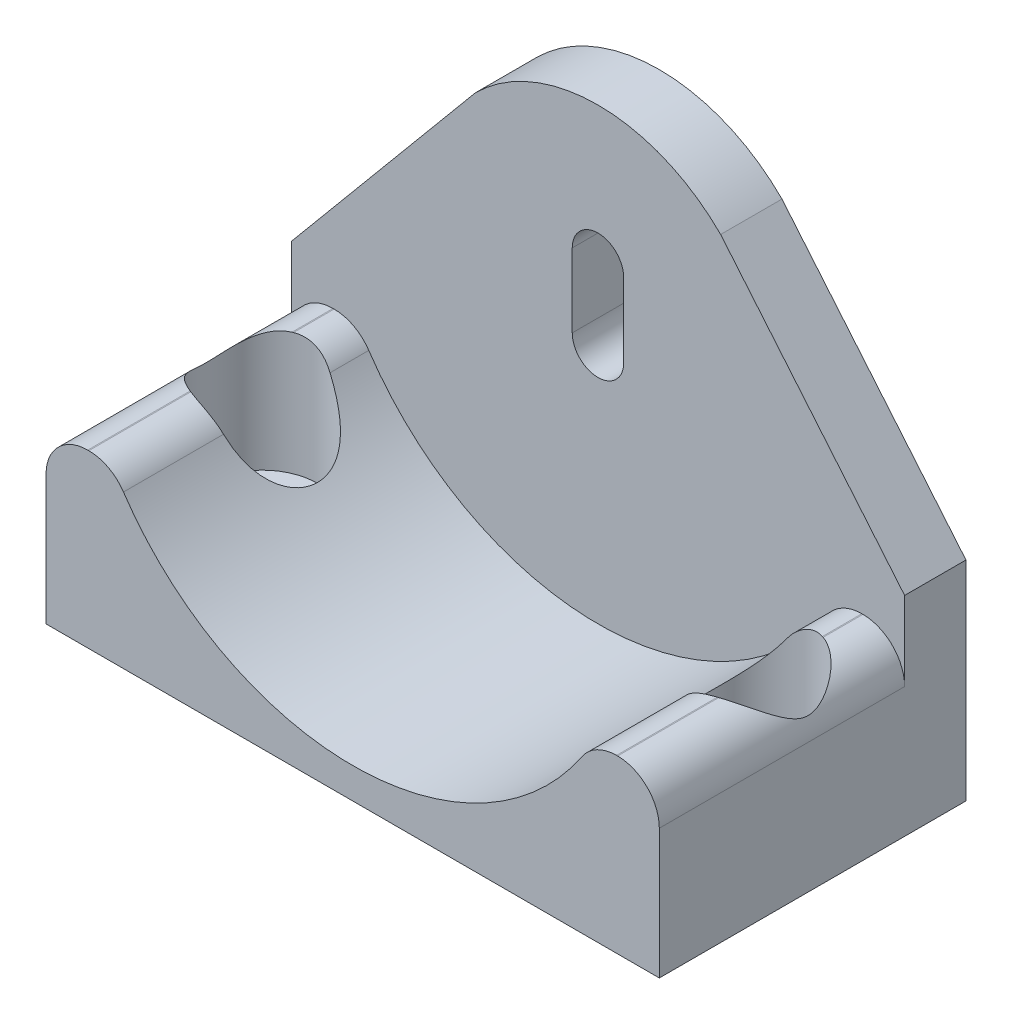
from build123d import *

# Parameters (mm, degrees)
EXTRUDE_1_DEPTH     = 25
EXTRUDE_2_DEPTH     = 5
CUT_EXTRUDE_START   = -20
CUT_EXTRUDE_2_DEPTH = 20
FILLET_3_R          = 3.4
FILLET_4_R          = 3.4
SKETCH_5_R          = 2.6
CUT_EXTRUDE_3_DEPTH = 20
SKETCH_7_R          = 4.5
CUT_EXTRUDE_5_DEPTH = 9.98


with BuildPart() as part:
    # 草图1 → 凸台-拉伸1 (new body)
    with BuildSketch(Plane.XY):
        with BuildLine():
            Line((-24.33363023, 3.038194444), (-28.298611111, 3.038194444))
            Line((-28.298611111, 3.038194444), (-28.298611111, -13.975694444))
            Line((-28.298611111, -13.975694444), (21.701388889, -13.975694444))
            Line((21.701388889, -13.975694444), (21.701388889, 3.038194444))
            Line((21.701388889, 3.038194444), (17.736408008, 3.038194444))
            ThreePointArc((17.736408008, 3.038194444), (-3.298611111, -11.475694444), (-24.33363023, 3.038194444))
        make_face()
    extrude(amount=EXTRUDE_1_DEPTH)

    # 草图1<5> → 凸台-拉伸2 (add)
    with BuildSketch(Plane.XY):
        with BuildLine():
            Line((-13.298611111, 21.024305556), (-28.298611111, 3.038194444))
            Line((-28.298611111, 3.038194444), (-24.33363023, 3.038194444))
            ThreePointArc((-24.33363023, 3.038194444), (-3.298611111, -11.475694444), (17.736408008, 3.038194444))
            Line((17.736408008, 3.038194444), (21.701388889, 3.038194444))
            Line((21.701388889, 3.038194444), (6.701388889, 21.024305556))
            ThreePointArc((6.701388889, 21.024305556), (-3.298611111, 25.166441179), (-13.298611111, 21.024305556))
        make_face()
        with BuildLine():
            ThreePointArc((-5.398611111, 14.024305556), (-3.298611111, 16.124305556), (-1.198611111, 14.024305556))
            Line((-1.198611111, 14.024305556), (-1.198611111, 8.024305556))
            ThreePointArc((-1.198611111, 8.024305556), (-3.298611111, 5.924305556), (-5.398611111, 8.024305556))
            Line((-5.398611111, 8.024305556), (-5.398611111, 14.024305556))
        make_face(mode=Mode.SUBTRACT)
    extrude(amount=EXTRUDE_2_DEPTH)

    # 草图3 → 切除-拉伸2 (cut)
    with BuildSketch(Plane.XY.offset(25).offset(CUT_EXTRUDE_START)):
        with BuildLine():
            Line((-28.298611111, 3.038194444), (-28.298611111, 0))
            Line((-28.298611111, 0), (-22.912756186, 0))
            ThreePointArc((-22.912756186, 0), (-23.679884226, 1.492584503), (-24.33363023, 3.038194444))
            Line((-24.33363023, 3.038194444), (-28.298611111, 3.038194444))
        make_face()
        with BuildLine():
            ThreePointArc((17.736408008, 3.038194444), (17.082662004, 1.492584503), (16.315533964, 0))
            Line((16.315533964, 0), (21.701388889, 0))
            Line((21.701388889, 0), (21.701388889, 3.038194444))
            Line((21.701388889, 3.038194444), (17.736408008, 3.038194444))
        make_face()
    extrude(amount=CUT_EXTRUDE_2_DEPTH, mode=Mode.SUBTRACT)

    # 圆角3
    fillet_3_edges = [part.edges().sort_by_distance(p)[0] for p in [
        (-22.912756186, 0, 15),
        (-28.298611111, 0, 15),
    ]]
    fillet(fillet_3_edges, radius=FILLET_3_R)

    # 圆角4
    fillet_4_edges = [part.edges().sort_by_distance(p)[0] for p in [
        (21.701388889, 0, 15),
        (16.315533964, 0, 15),
    ]]
    fillet(fillet_4_edges, radius=FILLET_4_R)

    # 草图5 → 切除-拉伸3 (cut)
    with BuildSketch(Plane(origin=(0, -13.975694444, 0), x_dir=(-1, 0, 0), z_dir=(0, -1, 0))):
        with Locations((23.159932347, -12.5)):
            Circle(SKETCH_5_R)
        with Locations((-16.840067653, -12.5)):
            Circle(SKETCH_5_R)
    extrude(amount=-CUT_EXTRUDE_3_DEPTH, mode=Mode.SUBTRACT)

    # 草图7 → 切除-拉伸5 (cut)
    with BuildSketch(Plane(origin=(0, 0, 0), x_dir=(1, 0, 0), z_dir=(0, 1, 0))):
        with Locations((-23.159932347, -12.5)):
            Circle(SKETCH_7_R)
        with Locations((16.840067653, -12.5)):
            Circle(SKETCH_7_R)
    extrude(amount=-CUT_EXTRUDE_5_DEPTH, mode=Mode.SUBTRACT)


solid = part.part
